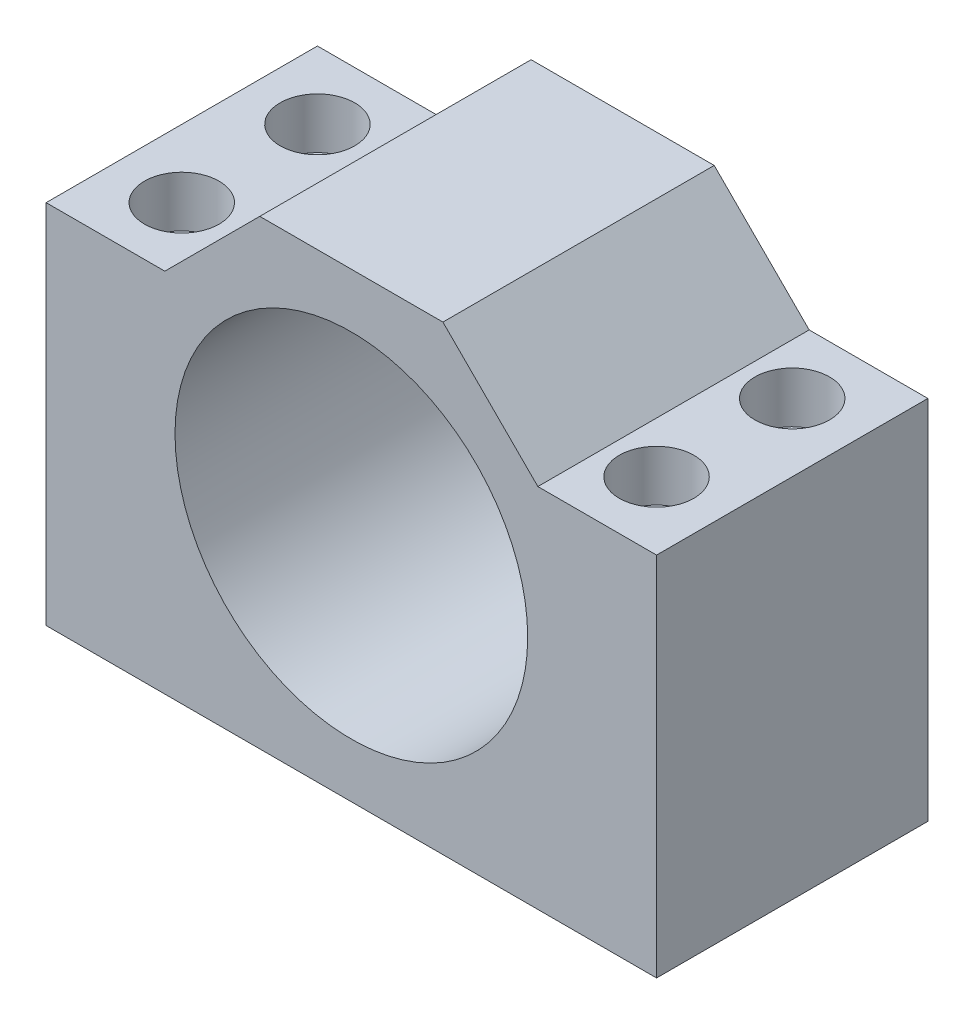
from build123d import *

# Parameters (mm, degrees)
SKETCH1_R         = 26
EXTRUSION1_DEPTH  = 40
HOLE1_D           = 6.6
HOLE1_CBORE_D     = 11
HOLE1_CBORE_DEPTH = 7.499997


with BuildPart() as part:
    # Sketch1 → Extrusion1 (new body)
    with BuildSketch(Plane.XY):
        Polygon((21.365726522, 9.909240265), (3.865726522, 9.909240265), (3.865726522, -44.090759735), (93.865726522, -44.090759735), (93.865726522, 9.909240265), (76.365726522, 9.909240265), (62.365726522, 23.909240265), (35.365726522, 23.909240265), align=None)
        with Locations((48.865726522, -10.090759735)):
            Circle(SKETCH1_R, mode=Mode.SUBTRACT)
    extrude(amount=EXTRUSION1_DEPTH)

    # Hole1 (through all)
    with Locations(Plane(origin=(0, 9.909240265, 0), x_dir=(1, 0, 0), z_dir=(0, 1, 0))):
        with Locations((13.865726522, -10), (13.865726522, -30), (83.865726522, -10), (83.865726522, -30)):
            CounterBoreHole(HOLE1_D / 2, HOLE1_CBORE_D / 2, HOLE1_CBORE_DEPTH)


solid = part.part
